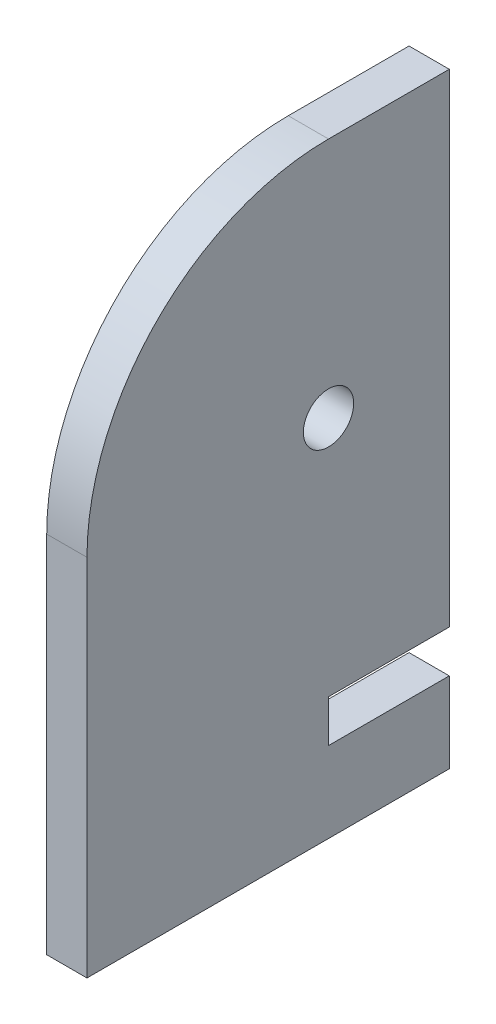
from build123d import *

# Parameters (mm, degrees)
SKETCH1_R           = 7.9375
BOSS_EXTRUDE1_DEPTH = 6.35


with BuildPart() as part:
    # Sketch1 → Boss-Extrude1 (new body, symmetric)
    with BuildSketch(Plane(origin=(0, 0, 0), x_dir=(0, 0, -1), z_dir=(1, 0, 0))):
        with BuildLine():
            Line((0, -76.2), (38.1, -76.2))
            Line((38.1, -76.2), (38.1, 76.2))
            Line((38.1, 76.2), (0, 76.2))
            ThreePointArc((0, 76.2), (-53.881536726, 53.881536726), (-76.2, 0))
            Line((-76.2, 0), (-76.2, -114.935))
            Line((-76.2, -114.935), (38.1, -114.935))
            Line((38.1, -114.935), (38.1, -89.535))
            Line((38.1, -89.535), (0, -89.535))
            Line((0, -89.535), (0, -76.2))
        make_face()
        Circle(SKETCH1_R, mode=Mode.SUBTRACT)
    extrude(amount=BOSS_EXTRUDE1_DEPTH, both=True)


solid = part.part
